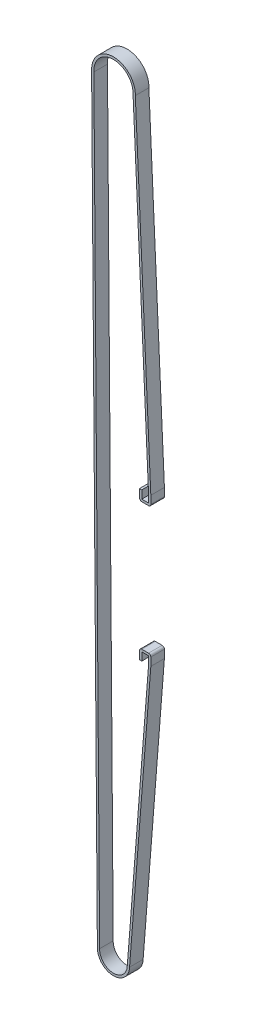
from build123d import *

# Parameters (mm, degrees)
BOSS_EXTRUDE1_DEPTH      = 3
BOSS_EXTRUDE1_DEPTH_BACK = 3
FILLET1_R                = 1


with BuildPart() as part:
    # Sketch2 → Boss-Extrude1 (new, two sides: drawn at the far end of the back side and taken through both)
    with BuildSketch(Plane(origin=(58.08391713634872, 121.43198942232709, 69.51869342732661), x_dir=(0.9993220722541541, -0.03681570189013682, 0), z_dir=(-1e-17, -3.5e-15, 1)).offset(-BOSS_EXTRUDE1_DEPTH_BACK)):
        with BuildLine():
            ThreePointArc((18.431354186205805, -334.4850073073481), (12.322654184920047, -340.5937073086338), (6.213954183634288, -334.4850073073481))
            Line((6.213954183634306, -334.4850073073481), (-8.624506729994131, -0.7684841044992936))
            ThreePointArc((-8.624506729991177, -0.7684841044991735), (-8.65013007423404, -0.38462170162740245), (-8.658676813147078, -1.6281e-13))
            ThreePointArc((-8.658676813147078, -1.6281e-13), (-1.47473e-12, 8.658676813145437), (8.658676813144126, -1.6653e-13))
            Line((8.658676813144126, -1.6653e-13), (21.0012414551849, -149.0397805610325))
            Line((21.0012414551849, -149.0397805610325), (21.13193719689482, -152.58737391753476))
            Line((21.13193719689482, -152.58737391753476), (18.133970980132357, -152.69782102320517))
            Line((18.133970980132357, -152.69782102320517), (18.003275238422436, -149.15022766670293))
            Line((18.003275238422436, -149.15022766670293), (17.00395316616828, -149.187043368593))
            Line((17.00395316616828, -149.187043368593), (17.171464609768407, -153.73395879734946))
            Line((17.171464609768407, -153.73395879734946), (22.168074971039157, -153.54988028789876))
            Line((22.168074971039157, -153.54988028789876), (22.00294469020588, -149.06759892527108))
            Line((22.00294469020588, -149.06759892527108), (9.659999999998522, -1.7053e-13))
            ThreePointArc((9.659999999998522, -1.6653e-13), (-1.47867e-12, 9.659999999999831), (-9.660000000001478, -1.6979e-13))
            Line((-9.660000000001478, -1.6653e-13), (-9.621878236414362, -0.8573559375786474))
            Line((-9.621878236414362, -0.8573559375786474), (5.212654183767356, -334.4850073073481))
            ThreePointArc((5.2126541837673726, -334.4850073073481), (12.322654184920088, -341.5950073085008), (19.43265418607275, -334.48500730734804))
            Line((19.43265418607274, -334.48500730734804), (24.411992001243018, -214.4585605917896))
            Line((24.411992001243018, -214.4585605917896), (24.24448055764289, -209.91164516303309))
            Line((24.24448055764289, -209.91164516303309), (19.247192268626275, -210.09574864780103))
            Line((19.247192268626275, -210.09574864780103), (19.414703712226398, -214.64266407655742))
            Line((19.414703712226398, -214.64266407655742), (20.414703712226398, -214.60582339935002))
            Line((20.414703712226398, -214.60582339935002), (20.284007970516445, -211.05823004284775))
            Line((20.284007970516445, -211.05823004284775), (23.28197418727881, -210.94778293717735))
            Line((23.28197418727881, -210.94778293717735), (23.412669928988862, -214.4953762936796))
            Line((23.412669928988862, -214.4953762936796), (18.431354186205787, -334.4850073073481))
        make_face()
    extrude(amount=BOSS_EXTRUDE1_DEPTH + BOSS_EXTRUDE1_DEPTH_BACK)

    # Fillet1
    fillet1_edges = [part.edges().sort_by_distance(p)[0] for p in [
        (69.5832387487039, -89.22992838096525, 69.51869342732587),
        (74.58391713634757, -89.22992838096522, 69.51869342732587),
        (69.58391713634755, -32.829928380965185, 69.51869342732607),
        (74.58391713634754, -32.829928380965185, 69.51869342732607),
    ]]
    fillet(fillet1_edges, radius=FILLET1_R)


solid = part.part
